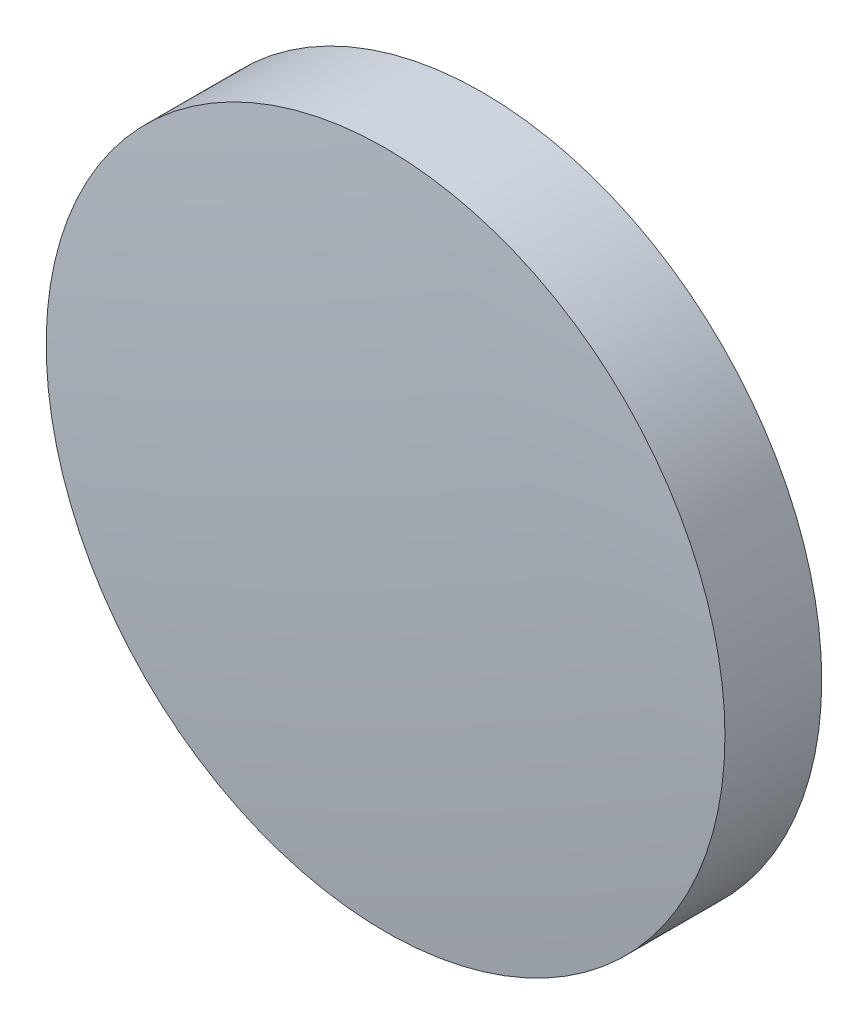
from build123d import *


with BuildPart() as part:
    # Sketch2 → Revolve1 (revolve)
    with BuildSketch(Plane(origin=(0, 0, 0), x_dir=(0, 0, -1), z_dir=(1, 0, 0))):
        with BuildLine():
            Line((-1.2, 0), (1.2, 0))
            ThreePointArc((1.2, 0), (1.126328432, 3.178413392), (0.905471962, 6.35))
            Line((0.905471962, 6.35), (-0.905471962, 6.35))
            ThreePointArc((-0.905471962, 6.35), (-1.126328432, 3.178413392), (-1.2, 0))
        make_face()
    revolve(axis=Axis((0, 0, 1.2), (0, 0, -1)))


solid = part.part
